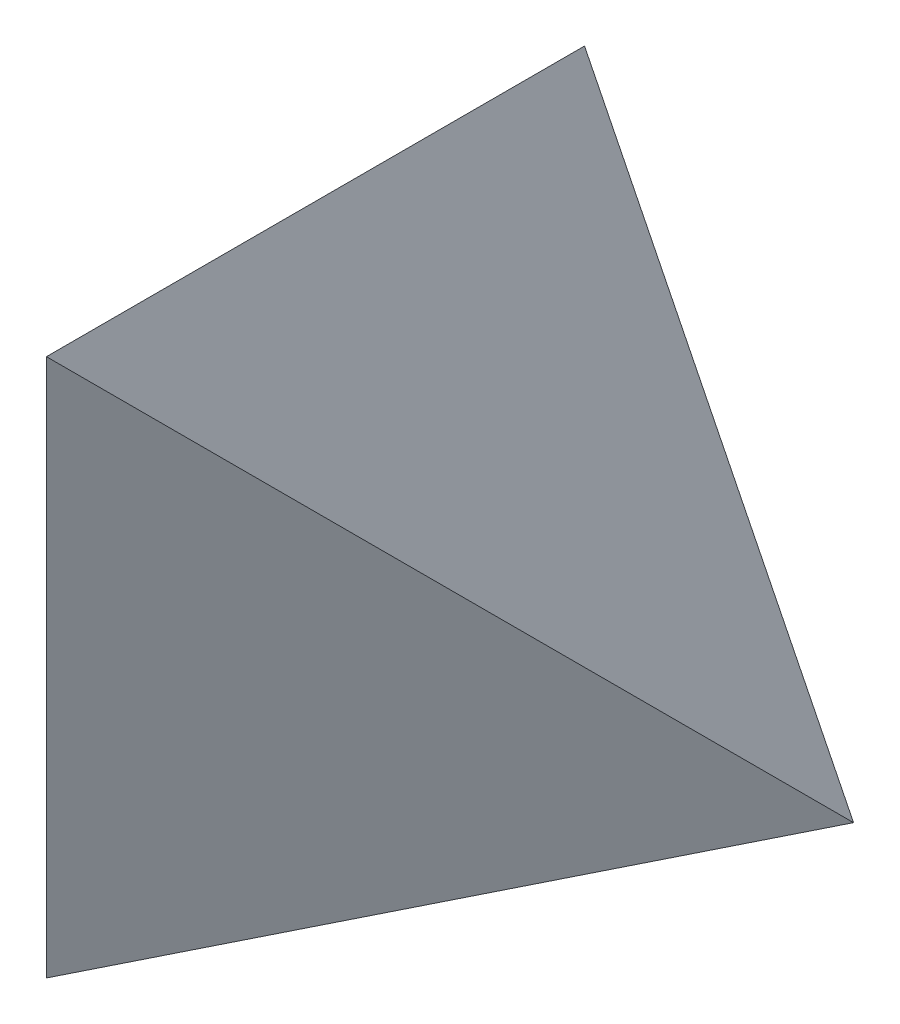
from build123d import *

# Parameters (mm, degrees)
BOSS_EXTRUDE1_DEPTH = 40
CUT_EXTRUDE1_DEPTH  = 40


with BuildPart() as part:
    # Sketch1 → Boss-Extrude1 (new body)
    with BuildSketch(Plane.XY):
        Polygon((0, 0), (20, 40), (40, 0), align=None)
    extrude(amount=BOSS_EXTRUDE1_DEPTH)

    # Sketch2 → Cut-Extrude1 (cut)
    with BuildSketch(Plane(origin=(0, 0, 0), x_dir=(1, 0, 0), z_dir=(0, 1, 0))):
        Polygon((20, -40), (0, 0), (0, -40), align=None)
        Polygon((40, 0), (20, -40), (40, -40), align=None)
    extrude(amount=CUT_EXTRUDE1_DEPTH, mode=Mode.SUBTRACT)


solid = part.part
